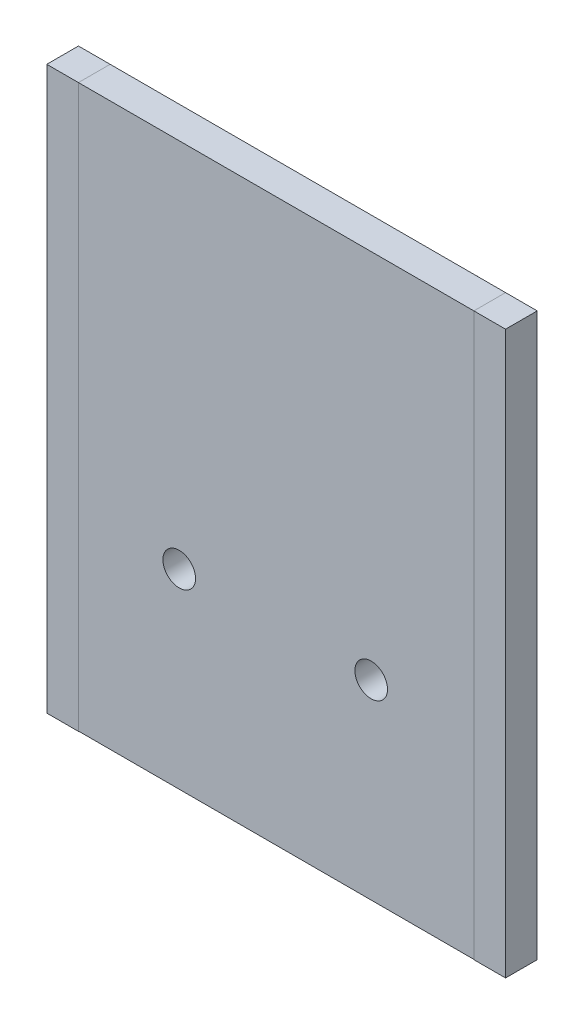
from build123d import *

# Parameters (mm, degrees)
SKETCH_1_R        = 1.7
EXTRUDE_1_DEPTH   = 3.3
SKETCH_2_W        = 3.3
SKETCH_2_H        = 58.544472475
EXTRUDE_2_DEPTH   = 3.3
EXTRUDE_2_2_DEPTH = 3.3


with BuildPart() as part:
    # 草圖1 → 填料-伸長1 (new body)
    with BuildSketch(Plane.XY):
        Polygon((21.926158038, 28.738964578), (21.926158038, -28.626702997), (-19.273841962, -28.626702997), (-19.273841962, 28.738964578), (-19.273841962, 29.888964578), (21.926158038, 29.888964578), align=None)
        with Locations((11.226158038, -8.761035422)):
            Circle(SKETCH_1_R, mode=Mode.SUBTRACT)
        with Locations((-8.773841962, -8.761035422)):
            Circle(SKETCH_1_R, mode=Mode.SUBTRACT)
    extrude(amount=-EXTRUDE_1_DEPTH)


with BuildPart() as body_2:
    # 草圖2 → 填料-伸長2 (new body)
    with BuildSketch(Plane.XY):
        with Locations((23.576158038, 0.61672834)):
            Rectangle(SKETCH_2_W, SKETCH_2_H)
    extrude(amount=-EXTRUDE_2_DEPTH)


with BuildPart() as body_3:
    # 草圖2 → Extrude 2 2 (new body)
    with BuildSketch(Plane.XY):
        with Locations((-20.923841962, 0.61672834)):
            Rectangle(SKETCH_2_W, SKETCH_2_H)
    extrude(amount=-EXTRUDE_2_2_DEPTH)


solid = Compound([part.part, body_2.part, body_3.part])
